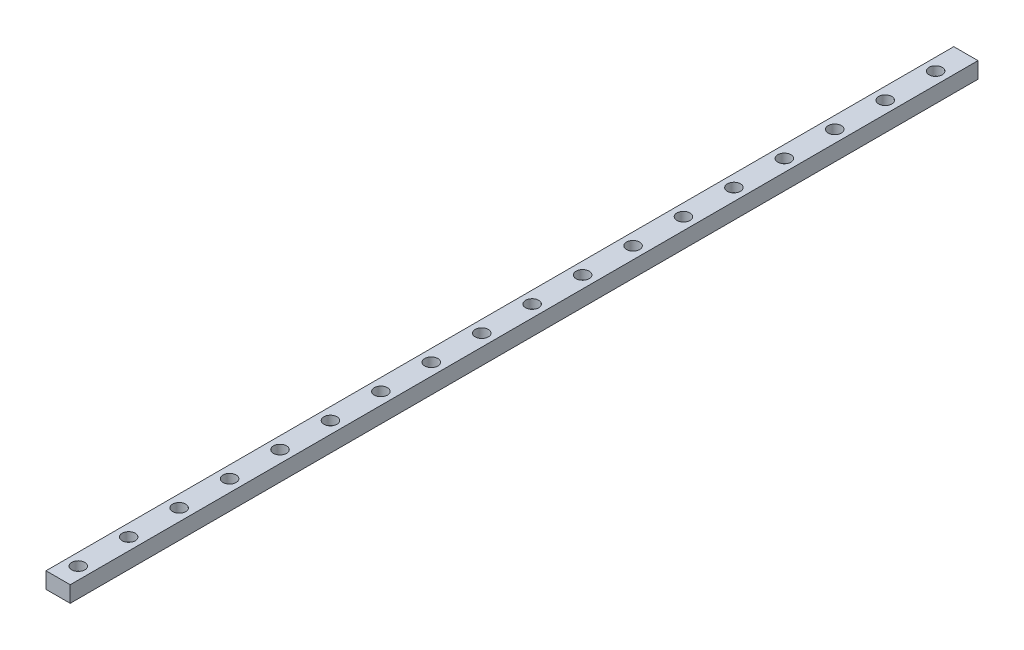
from build123d import *

# Parameters (mm, degrees)
SKETCH1_W                      = 12
SKETCH1_H                      = 8
BOSS_EXTRUDE1_DEPTH            = 450
CBORE_FOR_M3_SHCS1_D           = 3.4
CBORE_FOR_M3_SHCS1_CBORE_D     = 6.5
CBORE_FOR_M3_SHCS1_CBORE_DEPTH = 4.5


with BuildPart() as part:
    # Sketch1 → Boss-Extrude1 (new body)
    with BuildSketch(Plane.XY):
        with Locations((6, 4)):
            Rectangle(SKETCH1_W, SKETCH1_H)
    extrude(amount=BOSS_EXTRUDE1_DEPTH)

    # CBORE for M3 SHCS1 (through all)
    with Locations(Plane(origin=(0, 8, 0), x_dir=(1, 0, 0), z_dir=(0, 1, 0))):
        with Locations((6, -440), (6, -415), (6, -390), (6, -365), (6, -340), (6, -315), (6, -290), (6, -265), (6, -240), (6, -215), (6, -190), (6, -165), (6, -140), (6, -115), (6, -90), (6, -65), (6, -40), (6, -15)):
            CounterBoreHole(CBORE_FOR_M3_SHCS1_D / 2, CBORE_FOR_M3_SHCS1_CBORE_D / 2, CBORE_FOR_M3_SHCS1_CBORE_DEPTH)


solid = part.part
